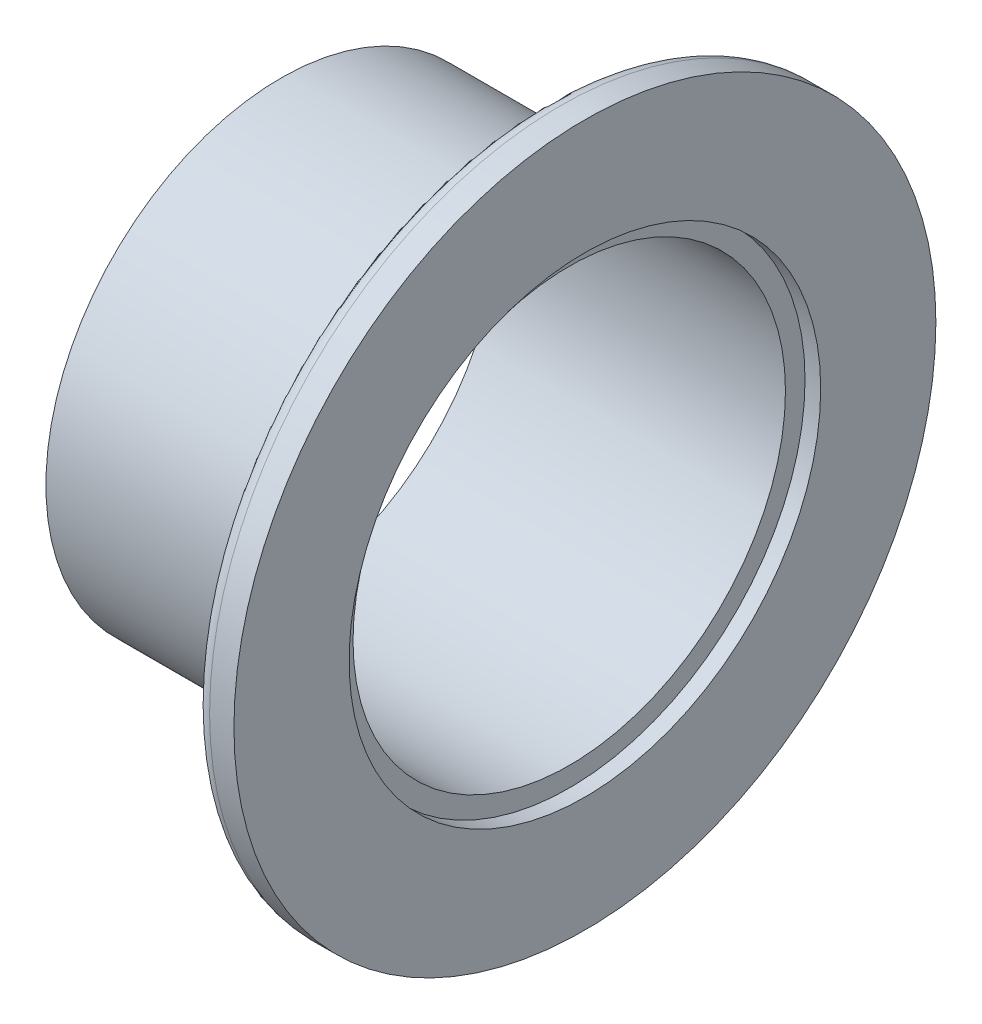
from build123d import *

# Parameters (mm, degrees)
SKETCH1_R           = 19.05
SKETCH1_R_2         = 17.526
BOSS_EXTRUDE1_DEPTH = 19.05
SKETCH2_R           = 28.448
BOSS_EXTRUDE2_DEPTH = 5.588
CHAMFER1_SIZE       = 7.493
CHAMFER1_SIZE2      = 2.727228965
FILLET2_R           = 1.27
SKETCH3_R           = 17.526
CUT_EXTRUDE1_DEPTH  = 6.5880001
SKETCH4_R           = 19.1135
SKETCH4_R_2         = 17.526
CUT_EXTRUDE2_DEPTH  = 1.27


with BuildPart() as part:
    # Sketch1 → Boss-Extrude1 (new body)
    with BuildSketch(Plane(origin=(0, 0, 0), x_dir=(0, 0, -1), z_dir=(1, 0, 0))):
        Circle(SKETCH1_R)
        Circle(SKETCH1_R_2, mode=Mode.SUBTRACT)
    extrude(amount=BOSS_EXTRUDE1_DEPTH)

    # Sketch2 → Boss-Extrude2 (add)
    with BuildSketch(Plane(origin=(19.05, 0, 0), x_dir=(0, 0, -1), z_dir=(1, 0, 0))):
        Circle(SKETCH2_R)
    extrude(amount=BOSS_EXTRUDE2_DEPTH)

    # Chamfer1
    chamfer1_edges = [part.edges().sort_by_distance(p)[0] for p in [
        (19.05, 0, 28.448),
    ]]
    chamfer1_side = [part.faces().sort_by_distance(p)[0] for p in [
        (19.05, 0, 27.643369052),
    ]]
    chamfer(chamfer1_edges, length=CHAMFER1_SIZE, length2=CHAMFER1_SIZE2, reference=chamfer1_side[0])

    # Fillet2
    fillet2_edges = [part.edges().sort_by_distance(p)[0] for p in [
        (21.777228965, 0, 28.448),
    ]]
    fillet(fillet2_edges, radius=FILLET2_R)

    # Sketch3 → Cut-Extrude1 (cut, through all)
    with BuildSketch(Plane.ZY.offset(-19.05)):
        Circle(SKETCH3_R)
    extrude(amount=-CUT_EXTRUDE1_DEPTH, mode=Mode.SUBTRACT)

    # Sketch4 → Cut-Extrude2 (cut)
    with BuildSketch(Plane(origin=(24.638, 0, 0), x_dir=(0, 0, -1), z_dir=(1, 0, 0))):
        Circle(SKETCH4_R)
        Circle(SKETCH4_R_2, mode=Mode.SUBTRACT)
    extrude(amount=-CUT_EXTRUDE2_DEPTH, mode=Mode.SUBTRACT)


solid = part.part
